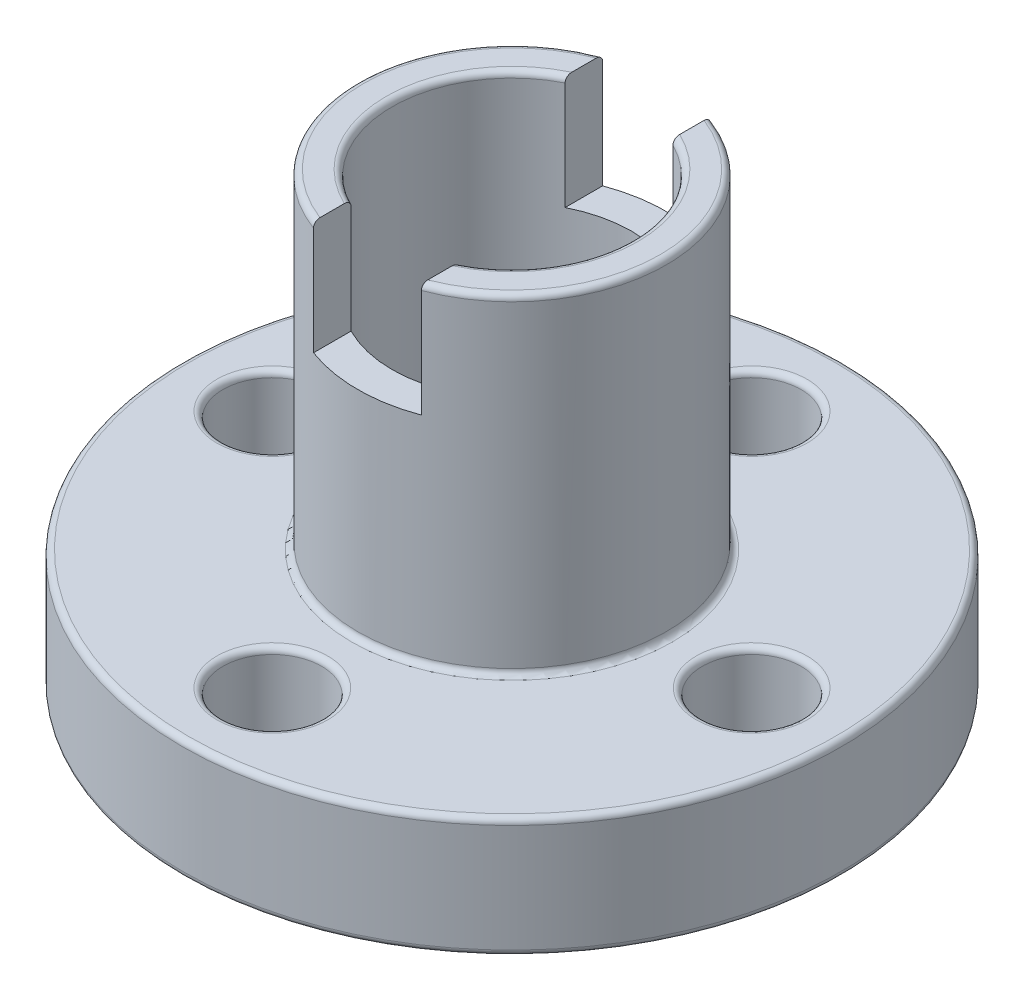
from build123d import *

# Parameters (mm, degrees)
SKETCH_1_R               = 11
SKETCH_1_R_2             = 1.65
SKETCH_1_R_3             = 5.15
EXTRUDE_1_DEPTH          = 4
SKETCH_1_3_R             = 5.15
SKETCH_1_3_R_2           = 4
EXTRUDE_2_DEPTH          = 15
FILLET_1_R               = 0.2
SKETCH_2_W               = 1.8
SKETCH_2_H               = 3.8
CUT_EXTRUDE_1_DEPTH      = 12
CUT_EXTRUDE_1_DEPTH_BACK = 12


with BuildPart() as part:
    # 草图1 → 凸台-拉伸1 (new body)
    with BuildSketch(Plane(origin=(0, 0, 0), x_dir=(1, 0, 0), z_dir=(0, 1, 0))):
        Circle(SKETCH_1_R)
        with Locations((-8, 0)):
            Circle(SKETCH_1_R_2, mode=Mode.SUBTRACT)
        with Locations((0, -8)):
            Circle(SKETCH_1_R_2, mode=Mode.SUBTRACT)
        with Locations((8, 0)):
            Circle(SKETCH_1_R_2, mode=Mode.SUBTRACT)
        with Locations((0, 8)):
            Circle(SKETCH_1_R_2, mode=Mode.SUBTRACT)
        Circle(SKETCH_1_R_3, mode=Mode.SUBTRACT)
    extrude(amount=EXTRUDE_1_DEPTH)

    # 草图1<3> → 凸台-拉伸2 (add)
    with BuildSketch(Plane(origin=(0, 0, 0), x_dir=(1, 0, 0), z_dir=(0, 1, 0))):
        Circle(SKETCH_1_3_R)
        Circle(SKETCH_1_3_R_2, mode=Mode.SUBTRACT)
    extrude(amount=EXTRUDE_2_DEPTH)

    # 圆角1
    fillet_1_edges = [part.edges().sort_by_distance(p)[0] for p in [
        (-1.65, 0, 8),
        (-9.65, 0, 0),
        (-9.65, 4, 0),
        (-1.65, 4, 8),
        (-4, 15, 0),
        (-5.15, 15, 0),
        (-4, 0, 0),
        (6.35, 4, 0),
        (-1.65, 4, -8),
        (-5.15, 4, 0),
        (-11, 4, 0),
        (-11, 0, 0),
        (-1.65, 0, -8),
        (6.35, 0, 0),
    ]]
    fillet(fillet_1_edges, radius=FILLET_1_R)

    # 草图2 → 切除-拉伸1 (cut, two sides)
    with BuildSketch(Plane.XY) as cut_extrude_1_sk:
        with Locations((-0.9, 13.1)):
            Rectangle(SKETCH_2_W, SKETCH_2_H)
        with Locations((0.9, 13.1)):
            Rectangle(SKETCH_2_W, SKETCH_2_H)
    extrude(amount=CUT_EXTRUDE_1_DEPTH, mode=Mode.SUBTRACT)
    extrude(cut_extrude_1_sk.sketch, amount=-CUT_EXTRUDE_1_DEPTH_BACK, mode=Mode.SUBTRACT)


solid = part.part
